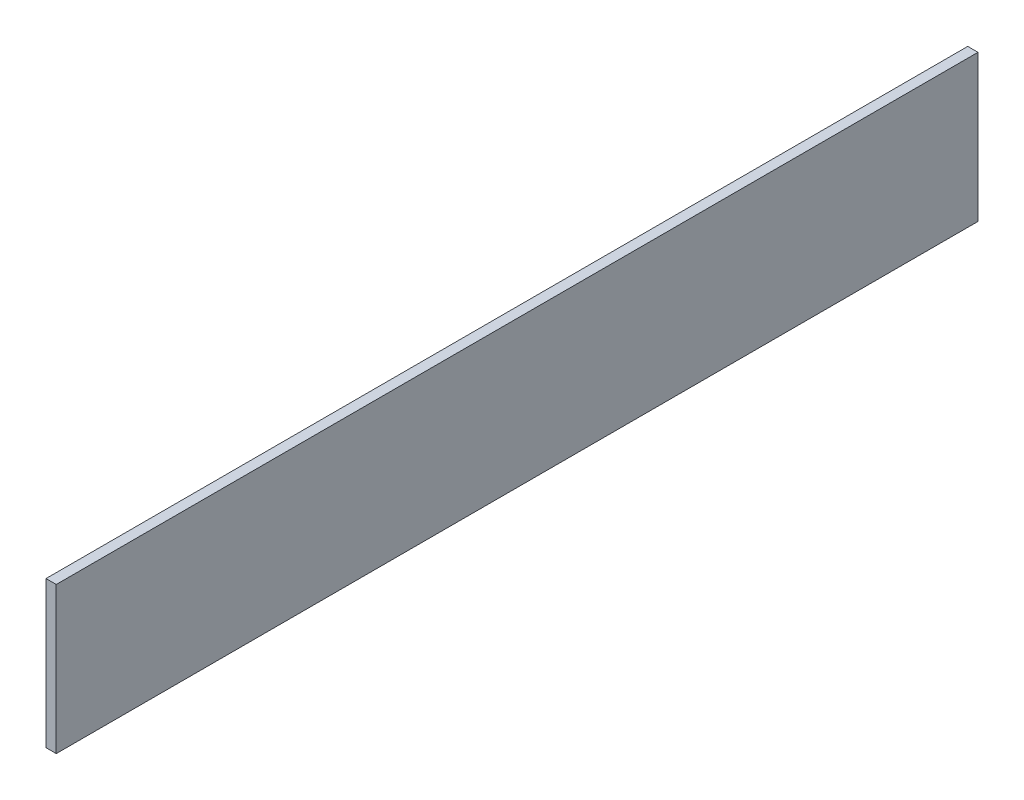
from build123d import *

# Parameters (mm, degrees)
SKIZZE1_W                       = 5
SKIZZE1_H                       = 71.52367356
AUFSATZ_LINEAR_AUSTRAGEN1_DEPTH = 450


with BuildPart() as part:
    # Skizze1 → Aufsatz-Linear austragen1 (new body)
    with BuildSketch(Plane.XY):
        with Locations((95, 218.26183678)):
            Rectangle(SKIZZE1_W, SKIZZE1_H)
    extrude(amount=AUFSATZ_LINEAR_AUSTRAGEN1_DEPTH)


solid = part.part
